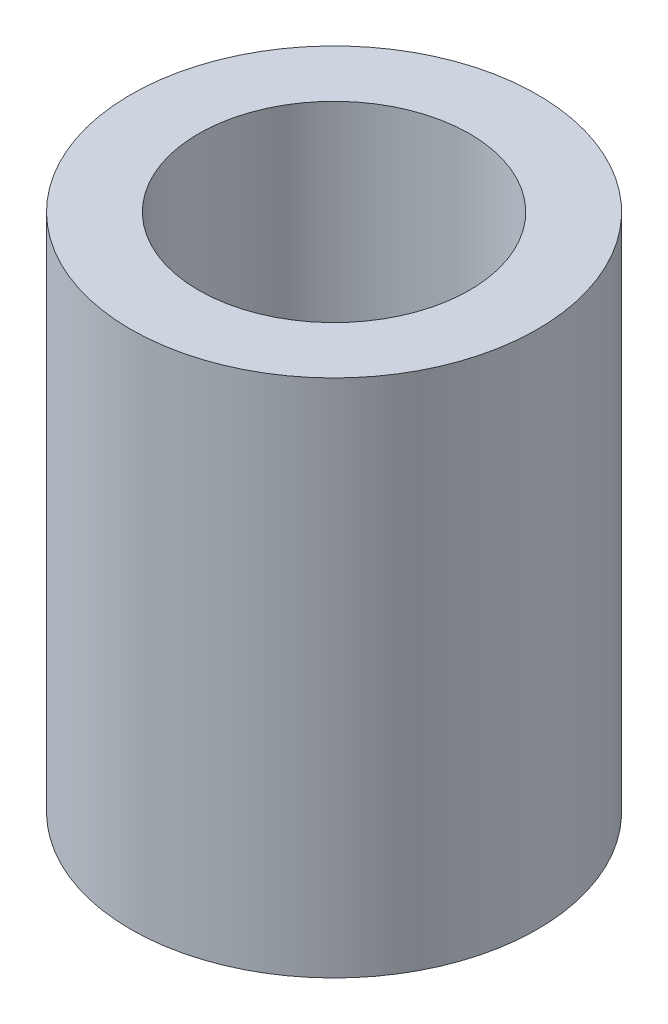
from build123d import *

# Parameters (mm, degrees)
SKETCH1_R           = 4.5
BOSS_EXTRUDE1_DEPTH = 5.5
SKETCH2_R           = 4.5
BOSS_EXTRUDE2_DEPTH = 6
SKETCH3_R           = 3
CUT_EXTRUDE1_DEPTH  = 5


with BuildPart() as part:
    # Sketch1 → Boss-Extrude1 (new body)
    with BuildSketch(Plane(origin=(0, 0, 0), x_dir=(1, 0, 0), z_dir=(0, 1, 0))):
        with Locations((-2.5, -1.5)):
            Circle(SKETCH1_R)
        with BuildLine():
            Line((-0.5, 0), (-4.5, 0))
            ThreePointArc((-4.5, 0), (-4.853553391, -0.146446609), (-5, -0.5))
            Line((-5, -0.5), (-5, -2.5))
            ThreePointArc((-5, -2.5), (-4.853553391, -2.853553391), (-4.5, -3))
            Line((-4.5, -3), (-0.5, -3))
            ThreePointArc((-0.5, -3), (-0.146446609, -2.853553391), (0, -2.5))
            Line((0, -2.5), (0, -0.5))
            ThreePointArc((0, -0.5), (-0.146446609, -0.146446609), (-0.5, 0))
        make_face(mode=Mode.SUBTRACT)
    extrude(amount=BOSS_EXTRUDE1_DEPTH)

    # Sketch2 → Boss-Extrude2 (add)
    with BuildSketch(Plane(origin=(0, 5.5, 0), x_dir=(1, 0, 0), z_dir=(0, 1, 0))):
        with Locations((-2.5, -1.5)):
            Circle(SKETCH2_R)
    extrude(amount=BOSS_EXTRUDE2_DEPTH)

    # Sketch3 → Cut-Extrude1 (cut)
    with BuildSketch(Plane(origin=(0, 11.5, 0), x_dir=(1, 0, 0), z_dir=(0, 1, 0))):
        with Locations((-2.5, -1.5)):
            Circle(SKETCH3_R)
    extrude(amount=-CUT_EXTRUDE1_DEPTH, mode=Mode.SUBTRACT)


solid = part.part
